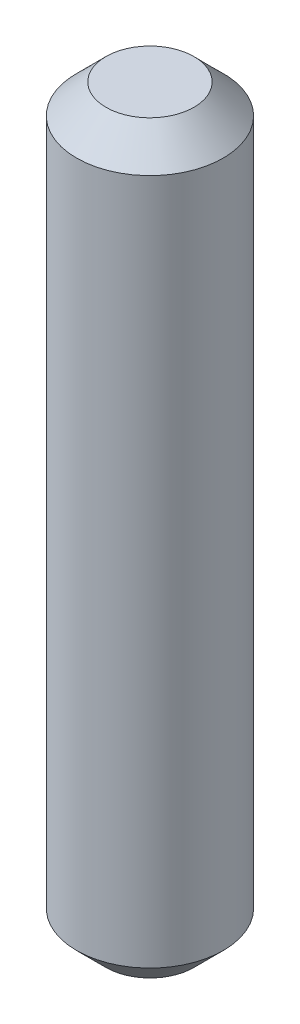
from build123d import *

# Parameters (mm, degrees)
SKETCH1_R           = 1.25
BOSS_EXTRUDE1_DEPTH = 12.7
CHAMFER1_SIZE       = 0.5


with BuildPart() as part:
    # Sketch1 → Boss-Extrude1 (new body)
    with BuildSketch(Plane(origin=(0, 0, 0), x_dir=(1, 0, 0), z_dir=(0, 1, 0))):
        Circle(SKETCH1_R)
    extrude(amount=BOSS_EXTRUDE1_DEPTH)

    # Chamfer1
    chamfer1_edges = [part.edges().sort_by_distance(p)[0] for p in [
        (-1.25, 0, 0),
        (-1.25, 12.7, 0),
    ]]
    chamfer(chamfer1_edges, length=CHAMFER1_SIZE)


solid = part.part
